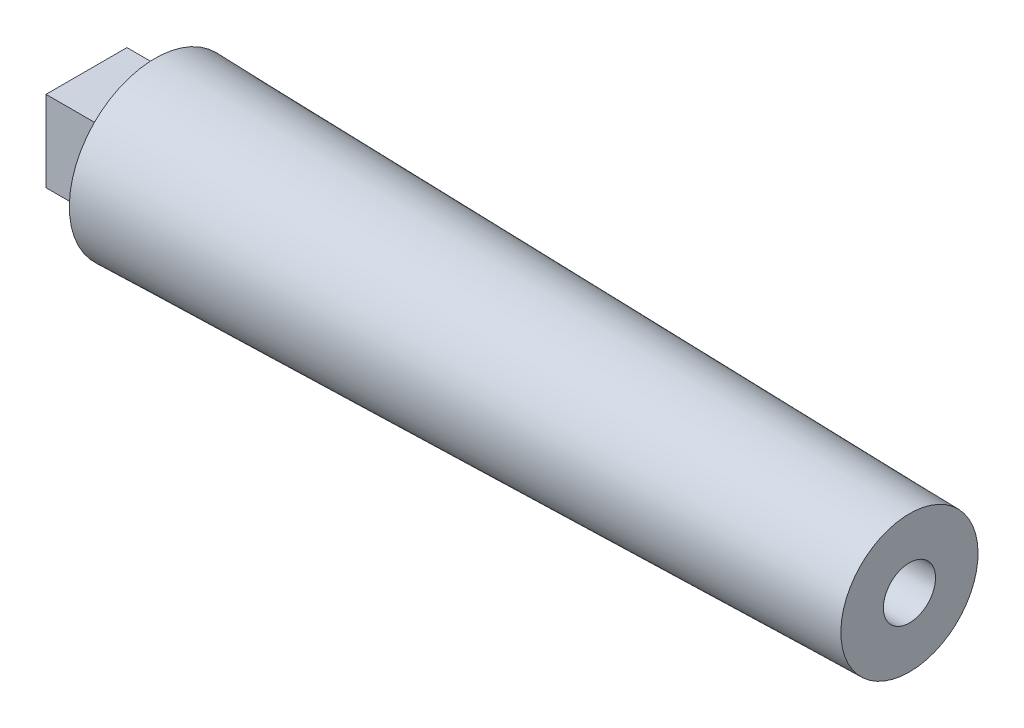
from build123d import *

# Parameters (mm, degrees)
SKETCH2_R           = 4.826
CUT_EXTRUDE1_DEPTH  = 25.4
SKETCH3_W           = 14.986
SKETCH3_H           = 14.986
BOSS_EXTRUDE1_DEPTH = 12.7


with BuildPart() as part:
    # Sketch1 → Revolve1 (revolve)
    with BuildSketch(Plane.XY):
        Polygon((12.7, 12.7), (12.7, 15.875), (152.4, 12.7), (152.4, 0), (12.7, 0), align=None)
    revolve(axis=Axis((12.7, 0, 0), (1, 0, 0)))

    # Sketch2 → Cut-Extrude1 (cut)
    with BuildSketch(Plane(origin=(152.4, 0, 0), x_dir=(0, 0, -1), z_dir=(1, 0, 0))):
        Circle(SKETCH2_R)
    extrude(amount=-CUT_EXTRUDE1_DEPTH, mode=Mode.SUBTRACT)

    # Sketch3 → Boss-Extrude1 (add)
    with BuildSketch(Plane.ZY.offset(-12.7)):
        Rectangle(SKETCH3_W, SKETCH3_H)
    extrude(amount=BOSS_EXTRUDE1_DEPTH)


solid = part.part
